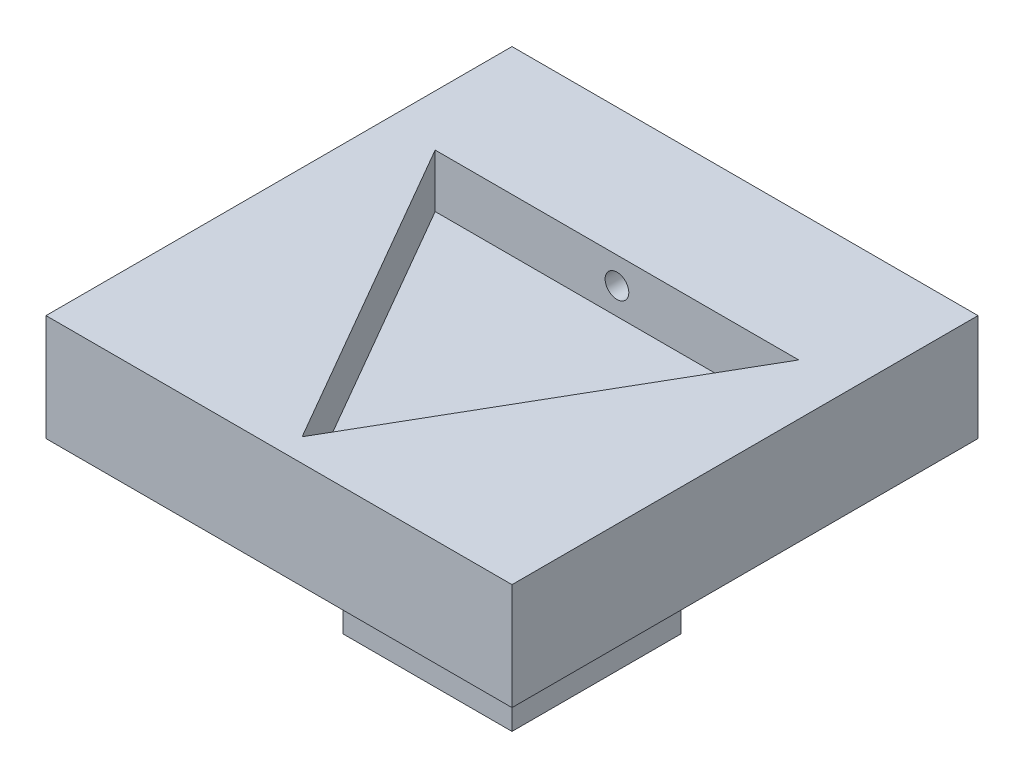
from build123d import *

# Parameters (mm, degrees)
SKETCH1_W                   = 35
SKETCH1_H                   = 35
EXTRUDE1_DEPTH              = 8
EXTRUDE2_DEPTH              = 4
F_2_56_TAPPED_HOLE1_D       = 1.778
F_2_56_TAPPED_HOLE1_DEPTH   = 9.617990411
SKETCH6_W                   = 12.7
SKETCH6_H                   = 12.7
EXTRUDE3_DEPTH              = 12.7
F_1_4_0_25_DIAMETER_HOLE1_D = 6.35
F_1_4_0_25_DIAMETER_HOLE2_D = 6.35
SKETCH14_W                  = 0.889
SKETCH14_H                  = 6.35


with BuildPart() as part:
    # Sketch1 → Extrude1 (new body)
    with BuildSketch(Plane(origin=(0, 0, 0), x_dir=(1, 0, 0), z_dir=(0, 1, 0))):
        Rectangle(SKETCH1_W, SKETCH1_H)
    extrude(amount=EXTRUDE1_DEPTH)

    # Sketch2 → Extrude2 (cut)
    with BuildSketch(Plane(origin=(0, 8, 0), x_dir=(1, 0, 0), z_dir=(0, 1, 0))):
        Polygon((0, -15.764019179), (13.652041074, 7.882009589), (-13.652041074, 7.882009589), align=None)
    extrude(amount=-EXTRUDE2_DEPTH, mode=Mode.SUBTRACT)

    # #2-56 Tapped Hole1
    with Locations(Plane(origin=(0, 6, -17.5), x_dir=(-1, 0, 0), z_dir=(0, 0, -1))):
        with Locations((0, 0)):
            Hole(F_2_56_TAPPED_HOLE1_D / 2, depth=F_2_56_TAPPED_HOLE1_DEPTH)

    # Sketch6 → Extrude3 (add)
    with BuildSketch(Plane.XZ):
        Rectangle(SKETCH6_W, SKETCH6_H)
    extrude(amount=EXTRUDE3_DEPTH)

    # 1/4 (0.25) Diameter Hole1 (through all)
    with Locations(Plane(origin=(0, -6.35, 6.35), x_dir=(1, 0, 0), z_dir=(0, 0, 1))):
        with Locations((0, 0)):
            Hole(F_1_4_0_25_DIAMETER_HOLE1_D / 2)

    # 1/4 (0.25) Diameter Hole2 (through all)
    with Locations(Plane(origin=(6.35, -6.35, 0), x_dir=(0, 0, 1), z_dir=(1, 0, 0))):
        with Locations((0, 0)):
            Hole(F_1_4_0_25_DIAMETER_HOLE2_D / 2)

    # Sketch14 → #2-56 Tapped Hole2 (revolve, cut)
    with BuildSketch(Plane(origin=(0, -12.7, 0), x_dir=(0, 0, -1), z_dir=(1, 0, 0))):
        with Locations((0.4445, 3.175)):
            Rectangle(SKETCH14_W, SKETCH14_H)
    revolve(axis=Axis((0, -19.05, 0), (0, 1, 0)), mode=Mode.SUBTRACT)


solid = part.part
